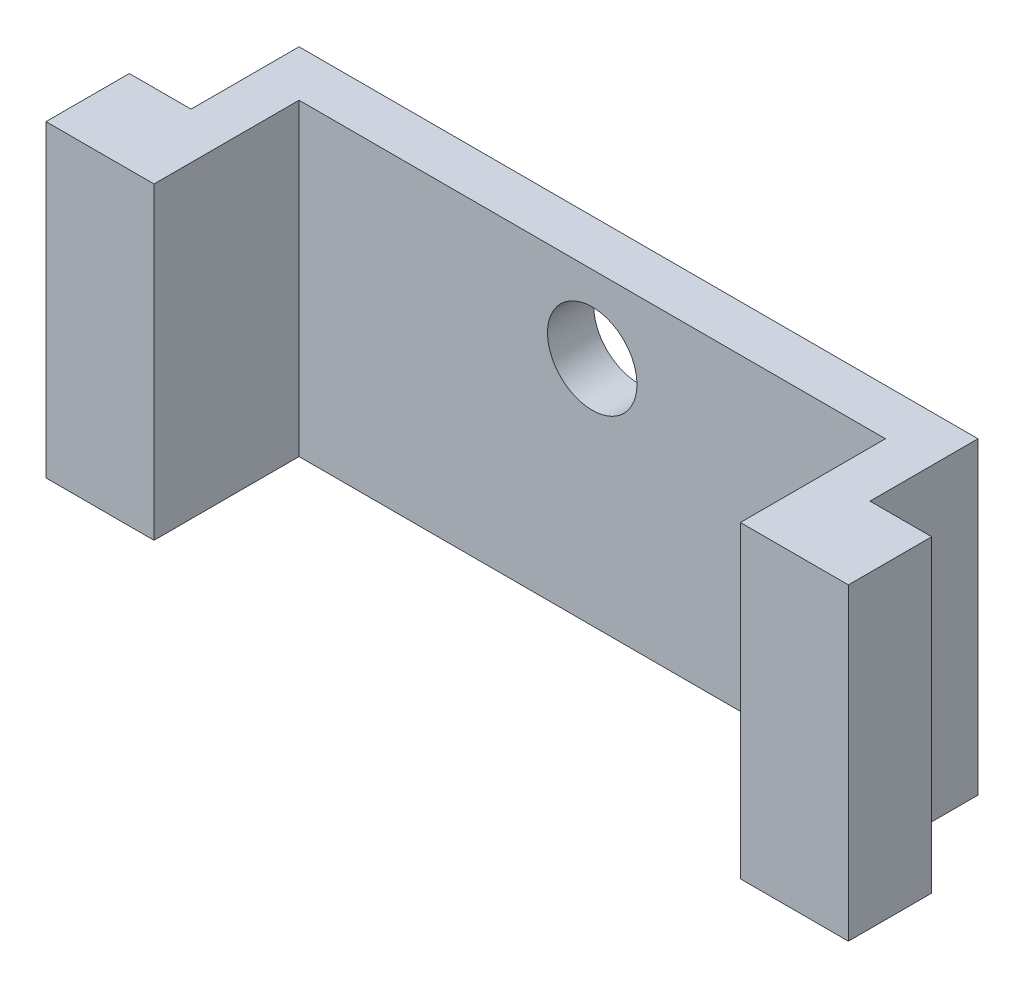
from build123d import *

# Parameters (mm, degrees)
SKETCH1_W           = 19
SKETCH1_H           = 1.5
SKETCH1_W_2         = 1.5
SKETCH1_H_2         = 4
BOSS_EXTRUDE1_DEPTH = 5
SKETCH2_W           = 3.5
SKETCH2_H           = 2
BOSS_EXTRUDE2_DEPTH = 5
SKETCH3_R           = 1.45
CUT_EXTRUDE1_DEPTH  = 5
BOSS_EXTRUDE3_DEPTH = 5
SKETCH5_W           = 3.5
SKETCH5_H           = 10
BOSS_EXTRUDE4_DEPTH = 0.7


with BuildPart() as part:
    # Sketch1 → Boss-Extrude1 (new body)
    with BuildSketch(Plane(origin=(0, 0, 0), x_dir=(1, 0, 0), z_dir=(0, 1, 0))):
        with Locations((6.456445993, -4.406794425)):
            Rectangle(SKETCH1_W, SKETCH1_H)
        with Locations((-3.793554007, -4.406794425)):
            Rectangle(SKETCH1_W_2, SKETCH1_H)
        with Locations((-3.793554007, -7.156794425)):
            Rectangle(SKETCH1_W_2, SKETCH1_H_2)
        with Locations((16.706445993, -4.406794425)):
            Rectangle(SKETCH1_W_2, SKETCH1_H)
        with Locations((16.706445993, -7.156794425)):
            Rectangle(SKETCH1_W_2, SKETCH1_H_2)
    extrude(amount=BOSS_EXTRUDE1_DEPTH)

    # Sketch2 → Boss-Extrude2 (add)
    with BuildSketch(Plane(origin=(0, 5, 0), x_dir=(1, 0, 0), z_dir=(0, 1, 0))):
        with Locations((-4.793554007, -8.156794425)):
            Rectangle(SKETCH2_W, SKETCH2_H)
        with Locations((17.706445993, -8.156794425)):
            Rectangle(SKETCH2_W, SKETCH2_H)
    extrude(amount=-BOSS_EXTRUDE2_DEPTH)

    # Sketch3 → Cut-Extrude1 (cut)
    with BuildSketch(Plane.XY.offset(5.156794425)):
        with Locations((6.456445993, 2.5)):
            Circle(SKETCH3_R)
    extrude(amount=-CUT_EXTRUDE1_DEPTH, mode=Mode.SUBTRACT)

    # Sketch4 → Boss-Extrude3 (add)
    with BuildSketch(Plane.XZ):
        Polygon((17.456445993, 3.656794425), (17.456445993, 7.156794425), (19.456445993, 7.156794425), (19.456445993, 9.156794425), (15.956445993, 9.156794425), (15.956445993, 5.156794425), (-3.043554007, 5.156794425), (-3.043554007, 9.156794425), (-6.543554007, 9.156794425), (-6.543554007, 7.156794425), (-4.543554007, 7.156794425), (-4.543554007, 3.656794425), align=None)
    extrude(amount=BOSS_EXTRUDE3_DEPTH)

    # Sketch5 → Boss-Extrude4 (add)
    with BuildSketch(Plane.XY.offset(9.156794425)):
        with Locations((17.706445993, 0)):
            Rectangle(SKETCH5_W, SKETCH5_H)
        with Locations((-4.793554007, 0)):
            Rectangle(SKETCH5_W, SKETCH5_H)
    extrude(amount=BOSS_EXTRUDE4_DEPTH)


solid = part.part
